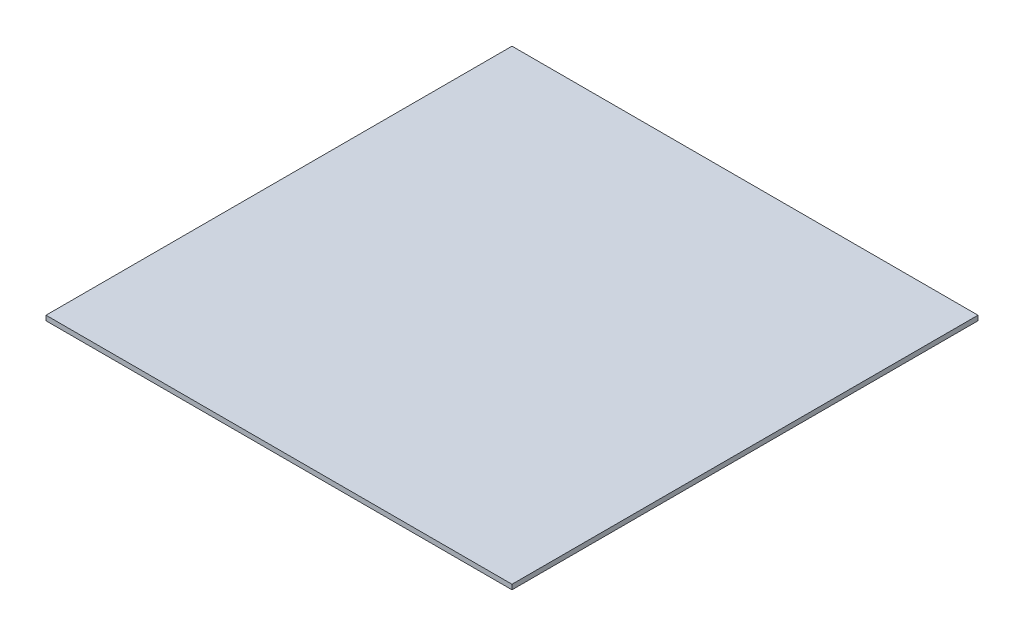
from build123d import *

# Parameters (mm, degrees)
SKETCH1_W           = 1219.2
SKETCH1_H           = 1219.2
BOSS_EXTRUDE1_DEPTH = 12.7


with BuildPart() as part:
    # Sketch1 → Boss-Extrude1 (new body)
    with BuildSketch(Plane(origin=(0, 0, 0), x_dir=(1, 0, 0), z_dir=(0, 1, 0))):
        with Locations((609.6, -609.6)):
            Rectangle(SKETCH1_W, SKETCH1_H)
    extrude(amount=BOSS_EXTRUDE1_DEPTH)


solid = part.part
